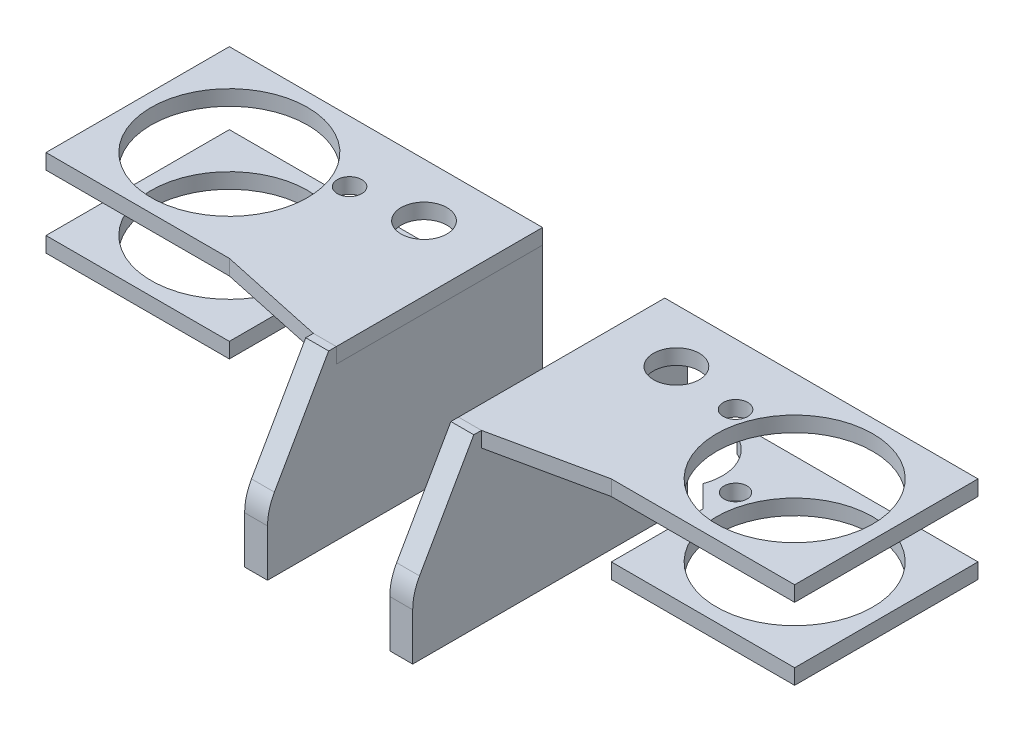
from build123d import *

# Parameters (mm, degrees)
BOSS_EXTRUDE1_DEPTH = 9.525
SKETCH7_R           = 32.5
SKETCH7_R_2         = 5.08
SKETCH7_R_3         = 9.525
BOSS_EXTRUDE2_DEPTH = 6.35
SKETCH8_R           = 32.5
SKETCH8_R_2         = 4.7625
BOSS_EXTRUDE3_DEPTH = 6.35


with BuildPart() as part:
    # Sketch6 → Boss-Extrude1 (new body)
    with BuildSketch(Plane(origin=(25.4, 0, 0), x_dir=(0, 0, -1), z_dir=(1, 0, 0))):
        with BuildLine():
            Line((-73.349578712, 43.014295617), (-50.8, 82.55))
            Line((-50.8, 82.55), (-47.625, 82.55))
            Line((-47.625, 82.55), (-47.625, 76.2))
            Line((-47.625, 76.2), (38.1, 76.2))
            Line((38.1, 76.2), (38.1, 12.7))
            Line((38.1, 12.7), (-76.2, 12.7))
            Line((-76.2, 12.7), (-76.2, 32.263386753))
            ThreePointArc((-76.2, 32.263386753), (-75.475293164, 37.824567898), (-73.349578712, 43.014295617))
        make_face()
    extrude(amount=BOSS_EXTRUDE1_DEPTH)


with BuildPart() as body_2:
    # Sketch7 → Boss-Extrude2 (new body)
    with BuildSketch(Plane(origin=(0, 76.2, 0), x_dir=(1, 0, 0), z_dir=(0, 1, 0))):
        Polygon((25.4, -47.625), (34.925, -47.625), (79.375, -38.1), (155.575, -38.1), (155.575, 38.1), (25.4, 38.1), align=None)
        with Locations((117.475, 0)):
            Circle(SKETCH7_R, mode=Mode.SUBTRACT)
        with Locations((80.209642092, 12.7)):
            Circle(SKETCH7_R_2, mode=Mode.SUBTRACT)
        with Locations((52.450625989, 15.875)):
            Circle(SKETCH7_R_3, mode=Mode.SUBTRACT)
    extrude(amount=BOSS_EXTRUDE2_DEPTH)


with BuildPart() as body_3:
    # Sketch8 → Boss-Extrude3 (new body)
    with BuildSketch(Plane(origin=(0, 52.675, 0), x_dir=(-1, 0, 0), z_dir=(0, -1, 0))):
        with BuildLine():
            Line((-60.325, 33.221375239), (-60.325, 38.1))
            Line((-60.325, 38.1), (-79.375, 38.1))
            Line((-79.375, 38.1), (-155.575, 38.1))
            Line((-155.575, 38.1), (-155.575, -38.1))
            Line((-155.575, -38.1), (-79.375, -38.1))
            Line((-79.375, -38.1), (-79.375, 0))
            Line((-79.375, 0), (-70.260632831, 9.114367169))
            ThreePointArc((-70.260632831, 9.114367169), (-70.063371785, 23.134041639), (-60.325, 33.221375239))
        make_face()
        with Locations((-117.475, 0)):
            Circle(SKETCH8_R, mode=Mode.SUBTRACT)
        with Locations((-80.209642092, 12.7)):
            Circle(SKETCH8_R_2, mode=Mode.SUBTRACT)
    extrude(amount=BOSS_EXTRUDE3_DEPTH)


with BuildPart() as body_4:
    # Mirror2: mirrored copy
    add(part.part.mirror(Plane(origin=(0, 0, 0), x_dir=(0, 0, 1), z_dir=(1, 0, 0))))


with BuildPart() as body_5:
    # Mirror2 2: mirrored copy
    add(body_2.part.mirror(Plane(origin=(0, 0, 0), x_dir=(0, 0, 1), z_dir=(1, 0, 0))))


with BuildPart() as body_6:
    # Mirror2 3: mirrored copy
    add(body_3.part.mirror(Plane(origin=(0, 0, 0), x_dir=(0, 0, 1), z_dir=(1, 0, 0))))


solid = Compound([part.part, body_2.part, body_3.part, body_4.part, body_5.part, body_6.part])
